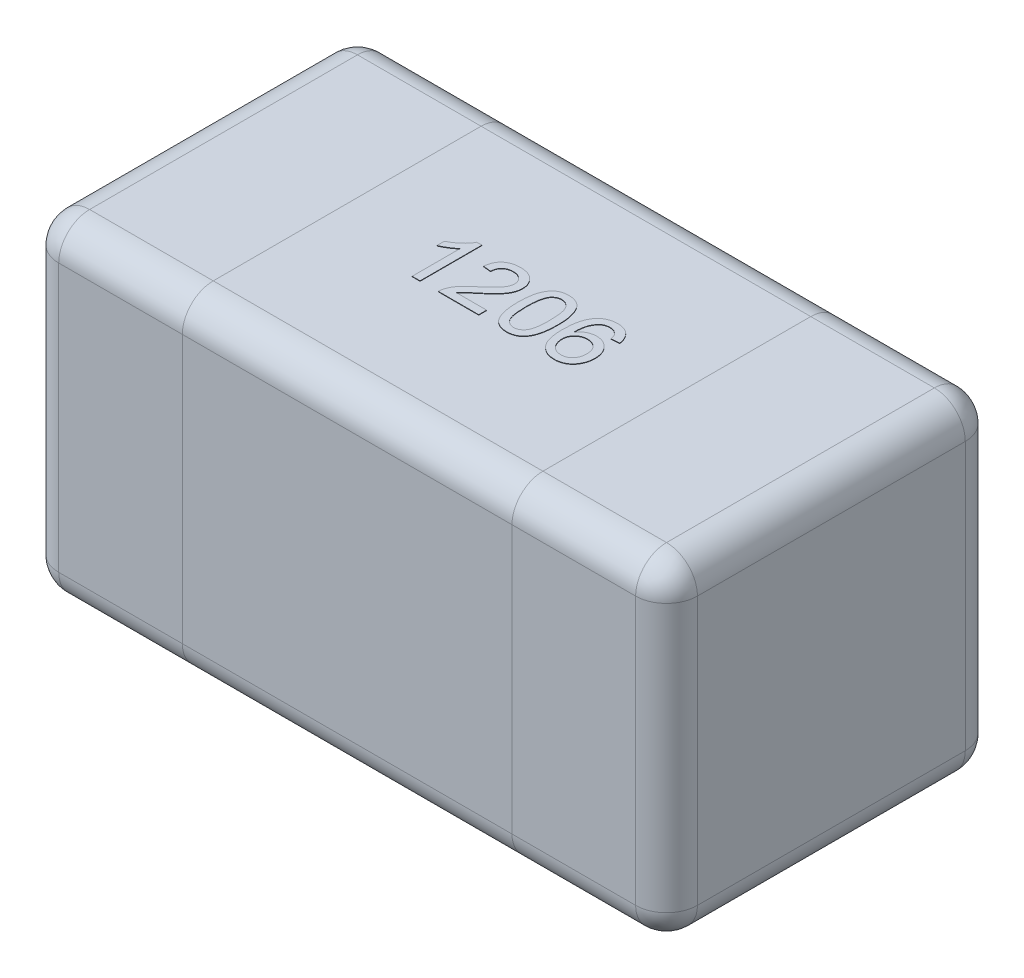
from build123d import *

# Parameters (mm, degrees)
SKETCH1_W      = 3.1
SKETCH1_H      = 1.6
EXTRUDE1_DEPTH = 1.6
FILLET1_R      = 0.15
EXTRUDE2_DEPTH = 0.002


with BuildPart() as part:
    # Sketch1 → Extrude1 (new body)
    with BuildSketch(Plane(origin=(0, 0, 0), x_dir=(1, 0, 0), z_dir=(0, 1, 0))):
        Rectangle(SKETCH1_W, SKETCH1_H)
    extrude(amount=EXTRUDE1_DEPTH)

    # Fillet1
    fillet1_edges = [part.edges().sort_by_distance(p)[0] for p in [
        (1.55, 1.6, 0),
        (0, 1.6, -0.8),
        (-1.55, 1.6, 0),
        (0, 0, -0.8),
        (1.55, 0, 0),
        (0, 0, 0.8),
        (-1.55, 0, 0),
        (0, 1.6, 0.8),
        (-1.55, 0.8, -0.8),
        (1.55, 0.8, -0.8),
        (1.55, 0.8, 0.8),
        (-1.55, 0.8, 0.8),
    ]]
    fillet(fillet1_edges, radius=FILLET1_R)

    # Sketch3 → Extrude2 (add)
    with BuildSketch(Plane(origin=(0, 1.6, 0), x_dir=(1, 0, 0), z_dir=(0, 1, 0))):
        with BuildLine():
            Line((-0.296153846, -0.15), (-0.334615385, -0.15))
            Line((-0.334615385, -0.15), (-0.334615385, 0.083774038))
            add(Edge.make_bspline(
                [(-0.334615385, 0.083774038), (-0.336830003, 0.081638311), (-0.341432846, 0.077199436), (-0.349213465, 0.070917319), (-0.35789763, 0.064550127), (-0.367372572, 0.05842736), (-0.377030672, 0.052663436), (-0.386363982, 0.047479672), (-0.39521668, 0.04309295), (-0.401047999, 0.040694273), (-0.403846154, 0.039543269)],
                knots=[0, 0, 0, 0, 9.226e-06, 1.9175e-05, 2.9969e-05, 4.1521e-05, 5.3002e-05, 6.3707e-05, 7.3544e-05, 8.2619e-05, 8.2619e-05, 8.2619e-05, 8.2619e-05], degree=3))
            Line((-0.403846154, 0.039543269), (-0.403846154, 0.075))
            add(Edge.make_bspline(
                [(-0.403846154, 0.075), (-0.399040034, 0.077475162), (-0.389567455, 0.082353558), (-0.37618475, 0.09077922), (-0.363690555, 0.099912985), (-0.352291699, 0.10975283), (-0.342073351, 0.119810917), (-0.333462201, 0.129959923), (-0.326256938, 0.139827828), (-0.322641922, 0.146709597), (-0.320913462, 0.15)],
                knots=[0, 0, 0, 0, 1.6212e-05, 3.1953e-05, 4.7386e-05, 6.26e-05, 7.7091e-05, 9.0349e-05, 0.000102505, 0.000113642, 0.000113642, 0.000113642, 0.000113642], degree=3))
            Line((-0.320913462, 0.15), (-0.296153846, 0.15))
            Line((-0.296153846, 0.15), (-0.296153846, -0.15))
        make_face()
        with BuildLine():
            Line((-0.011538462, -0.111538462), (-0.011538462, -0.15))
            Line((-0.011538462, -0.15), (-0.207692308, -0.15))
            add(Edge.make_bspline(
                [(-0.207692308, -0.15), (-0.207696323, -0.147714123), (-0.207704342, -0.14315003), (-0.206932024, -0.136400026), (-0.205722419, -0.129739566), (-0.204354719, -0.125468478), (-0.203665865, -0.123317308)],
                knots=[0, 0, 0, 0, 6.852e-06, 1.3681e-05, 2.0352e-05, 2.7121e-05, 2.7121e-05, 2.7121e-05, 2.7121e-05], degree=3))
            add(Edge.make_bspline(
                [(-0.203665865, -0.123317308), (-0.202393093, -0.119802551), (-0.199801518, -0.112645929), (-0.19455096, -0.102319922), (-0.188375063, -0.092056365), (-0.182361958, -0.08370038), (-0.176855252, -0.077024532), (-0.172237162, -0.071801454), (-0.167119471, -0.066455018), (-0.161506278, -0.060986201), (-0.155451607, -0.055359583), (-0.148947197, -0.049556401), (-0.141916239, -0.043684801), (-0.137007895, -0.039792861), (-0.134495192, -0.037800481)],
                knots=[0, 0, 0, 0, 1.1205e-05, 2.2816e-05, 3.4678e-05, 4.712e-05, 5.3653e-05, 6.0635e-05, 6.8031e-05, 7.5851e-05, 8.4142e-05, 9.2826e-05, 0.000101998, 0.000111618, 0.000111618, 0.000111618, 0.000111618], degree=3))
            add(Edge.make_bspline(
                [(-0.134495192, -0.037800481), (-0.130635061, -0.034551471), (-0.123202132, -0.028295295), (-0.112705672, -0.019011711), (-0.103118865, -0.010391377), (-0.094594368, -0.002283205), (-0.087062462, 0.005234162), (-0.080505461, 0.012143692), (-0.074866946, 0.018423822), (-0.070215752, 0.024301865), (-0.066291398, 0.029852373), (-0.062965854, 0.035266551), (-0.060194454, 0.040638972), (-0.057886249, 0.045952637), (-0.056060655, 0.05123027), (-0.054816253, 0.056487246), (-0.053972343, 0.061671403), (-0.053887909, 0.065120999), (-0.053846154, 0.066826923)],
                knots=[0, 0, 0, 0, 1.5136e-05, 2.9145e-05, 4.2036e-05, 5.3811e-05, 6.4435e-05, 7.3957e-05, 8.2386e-05, 8.9745e-05, 9.643e-05, 0.000102769, 0.00010879, 0.00011455, 0.000120137, 0.000125516, 0.000130743, 0.000135857, 0.000135857, 0.000135857, 0.000135857], degree=3))
            add(Edge.make_bspline(
                [(-0.053846154, 0.066826923), (-0.053887914, 0.068512943), (-0.053969845, 0.071820821), (-0.054747201, 0.076661881), (-0.055829343, 0.081323937), (-0.057578837, 0.085723063), (-0.059661262, 0.089989532), (-0.062332474, 0.093988532), (-0.065422517, 0.097819726), (-0.068960356, 0.101382104), (-0.072824504, 0.104724183), (-0.077142138, 0.107502263), (-0.081629679, 0.110003363), (-0.086441941, 0.11201439), (-0.091571106, 0.113491124), (-0.096979835, 0.114562852), (-0.10266727, 0.115242385), (-0.106548545, 0.115336486), (-0.108533654, 0.115384615)],
                knots=[0, 0, 0, 0, 5.054e-06, 9.915e-06, 1.4681e-05, 1.938e-05, 2.4083e-05, 2.89e-05, 3.3772e-05, 3.8829e-05, 4.3946e-05, 4.9063e-05, 5.4199e-05, 5.9345e-05, 6.4669e-05, 7.0185e-05, 7.5872e-05, 8.1827e-05, 8.1827e-05, 8.1827e-05, 8.1827e-05], degree=3))
            add(Edge.make_bspline(
                [(-0.108533654, 0.115384615), (-0.110618956, 0.115336725), (-0.114700045, 0.115242999), (-0.120665504, 0.114560756), (-0.126328674, 0.113518381), (-0.131676037, 0.111924678), (-0.136701084, 0.109917004), (-0.141383351, 0.107389877), (-0.145797819, 0.104537208), (-0.149805459, 0.101159863), (-0.153429516, 0.097415076), (-0.156646835, 0.093338135), (-0.159282944, 0.088850365), (-0.161459952, 0.084050442), (-0.163210448, 0.078923275), (-0.164481249, 0.07342967), (-0.165174098, 0.067585487), (-0.165313425, 0.063583392), (-0.165384615, 0.061538462)],
                knots=[0, 0, 0, 0, 6.255e-06, 1.2241e-05, 1.7992e-05, 2.3507e-05, 2.8953e-05, 3.4195e-05, 3.9446e-05, 4.4693e-05, 4.9878e-05, 5.506e-05, 6.0233e-05, 6.5451e-05, 7.0848e-05, 7.6461e-05, 8.2334e-05, 8.8471e-05, 8.8471e-05, 8.8471e-05, 8.8471e-05], degree=3))
            Line((-0.165384615, 0.061538462), (-0.203846154, 0.065384615))
            add(Edge.make_bspline(
                [(-0.203846154, 0.065384615), (-0.203452638, 0.068736632), (-0.202687086, 0.075257693), (-0.200780201, 0.084702351), (-0.198103106, 0.09348859), (-0.194899737, 0.101738909), (-0.190884012, 0.109312863), (-0.18634458, 0.11636711), (-0.18099053, 0.122677919), (-0.175075725, 0.128444216), (-0.168535362, 0.133525841), (-0.161430878, 0.137965346), (-0.153765522, 0.141678718), (-0.145581988, 0.144753235), (-0.136861488, 0.147085948), (-0.12761636, 0.148758724), (-0.117831734, 0.149789842), (-0.111120341, 0.149928948), (-0.107692308, 0.15)],
                knots=[0, 0, 0, 0, 1.0123e-05, 1.9693e-05, 2.8857e-05, 3.7651e-05, 4.6199e-05, 5.4533e-05, 6.2766e-05, 7.0968e-05, 7.9275e-05, 8.7563e-05, 9.6056e-05, 0.000104785, 0.00011375, 0.000123098, 0.000132946, 0.000143229, 0.000143229, 0.000143229, 0.000143229], degree=3))
            add(Edge.make_bspline(
                [(-0.107692308, 0.15), (-0.104223243, 0.149940596), (-0.097465484, 0.149824877), (-0.087618344, 0.14864084), (-0.078327294, 0.146796713), (-0.069558275, 0.144226564), (-0.061363096, 0.140856333), (-0.053735451, 0.136738671), (-0.046640172, 0.131913745), (-0.040195807, 0.126323636), (-0.034384754, 0.120221095), (-0.029292223, 0.113708369), (-0.025034622, 0.106813279), (-0.021409539, 0.09962981), (-0.018720681, 0.092006182), (-0.016829827, 0.084046037), (-0.015544936, 0.075742575), (-0.015438766, 0.070077103), (-0.015384615, 0.0671875)],
                knots=[0, 0, 0, 0, 1.0403e-05, 2.0265e-05, 2.9705e-05, 3.8794e-05, 4.7633e-05, 5.6238e-05, 6.4755e-05, 7.3321e-05, 8.178e-05, 9.0002e-05, 9.8073e-05, 0.000106055, 0.000114096, 0.000122258, 0.000130579, 0.00013924, 0.00013924, 0.00013924, 0.00013924], degree=3))
            add(Edge.make_bspline(
                [(-0.015384615, 0.0671875), (-0.015467303, 0.06421876), (-0.01563286, 0.058274728), (-0.016925056, 0.049390154), (-0.019136019, 0.040601997), (-0.022067165, 0.0318033), (-0.026071721, 0.022959142), (-0.031130797, 0.013947517), (-0.037407134, 0.004735138), (-0.04344321, -0.003096409), (-0.049061817, -0.009661219), (-0.054042181, -0.015064442), (-0.059804175, -0.020805005), (-0.066131643, -0.027081717), (-0.073282651, -0.033671804), (-0.081051734, -0.040772611), (-0.089608959, -0.048197271), (-0.095549342, -0.053269443), (-0.098617788, -0.055889423)],
                knots=[0, 0, 0, 0, 8.904e-06, 1.7828e-05, 2.6865e-05, 3.6063e-05, 4.5612e-05, 5.5944e-05, 6.7028e-05, 7.9024e-05, 8.5588e-05, 9.2946e-05, 0.000101063, 0.000109987, 0.000119681, 0.000130232, 0.000141562, 0.000153666, 0.000153666, 0.000153666, 0.000153666], degree=3))
            add(Edge.make_bspline(
                [(-0.098617788, -0.055889423), (-0.101245449, -0.058028619), (-0.106255994, -0.062107737), (-0.113384465, -0.068021343), (-0.119769407, -0.07344396), (-0.12556013, -0.078198712), (-0.130545741, -0.08251558), (-0.13490185, -0.086205504), (-0.138470198, -0.089454013), (-0.14390416, -0.094388563), (-0.150786737, -0.101422266), (-0.155858114, -0.108256719), (-0.158293269, -0.111538462)],
                knots=[0, 0, 0, 0, 1.0165e-05, 1.9383e-05, 2.7786e-05, 3.5295e-05, 4.1859e-05, 4.7569e-05, 5.242e-05, 5.6334e-05, 6.9594e-05, 8.1844e-05, 8.1844e-05, 8.1844e-05, 8.1844e-05], degree=3))
            Line((-0.158293269, -0.111538462), (-0.011538462, -0.111538462))
        make_face()
        with BuildLine():
            add(Edge.make_bspline(
                [(0.030769231, -0.002043269), (0.030807981, 0.002244006), (0.030883876, 0.010640973), (0.031354627, 0.022927244), (0.032176522, 0.034595007), (0.033403384, 0.045634129), (0.034856218, 0.056069528), (0.036744912, 0.06588631), (0.038869967, 0.075106502), (0.041419652, 0.083720493), (0.044220921, 0.091802347), (0.047399051, 0.0993391), (0.050974877, 0.106322761), (0.054772671, 0.112825754), (0.058992356, 0.118746931), (0.063379241, 0.124252464), (0.068252138, 0.129140445), (0.073408422, 0.13353664), (0.07892402, 0.137416027), (0.084769749, 0.140763469), (0.090923117, 0.143719019), (0.097501399, 0.145943957), (0.104368033, 0.147757753), (0.111575873, 0.149092003), (0.119132863, 0.149878588), (0.124297003, 0.149959072), (0.126923077, 0.15)],
                knots=[0, 0, 0, 0, 1.2862e-05, 2.5191e-05, 3.688e-05, 4.7943e-05, 5.8507e-05, 6.8478e-05, 7.7924e-05, 8.6881e-05, 9.5415e-05, 0.000103574, 0.000111395, 0.00011894, 0.000126142, 0.000133191, 0.000140033, 0.000146812, 0.000153498, 0.000160229, 0.000167003, 0.000173941, 0.000181025, 0.000188297, 0.00019591, 0.000203786, 0.000203786, 0.000203786, 0.000203786], degree=3))
            add(Edge.make_bspline(
                [(0.126923077, 0.15), (0.130775868, 0.149886731), (0.138344831, 0.149664209), (0.149395556, 0.147849358), (0.159810153, 0.144744777), (0.169581854, 0.140556563), (0.178543614, 0.135236725), (0.186546843, 0.128769652), (0.193505214, 0.121223246), (0.199342787, 0.112508085), (0.204445409, 0.102864591), (0.208978466, 0.092249481), (0.213076217, 0.080674651), (0.215984071, 0.070313561), (0.218058241, 0.061369501), (0.219431176, 0.053992694), (0.220570988, 0.046033077), (0.221444238, 0.037509907), (0.222160719, 0.028432744), (0.222714024, 0.018795935), (0.222994883, 0.008575397), (0.223049064, 0.001562641), (0.223076923, -0.002043269)],
                knots=[0, 0, 0, 0, 1.1554e-05, 2.2698e-05, 3.348e-05, 4.4085e-05, 5.4516e-05, 6.4643e-05, 7.485e-05, 8.5185e-05, 9.602e-05, 0.000107541, 0.000119781, 0.000132832, 0.000139801, 0.000147321, 0.000155335, 0.000163916, 0.000173019, 0.00018265, 0.000192871, 0.000203689, 0.000203689, 0.000203689, 0.000203689], degree=3))
            add(Edge.make_bspline(
                [(0.223076923, -0.002043269), (0.223037447, -0.006310407), (0.222960323, -0.0146471), (0.222502186, -0.026834856), (0.221630766, -0.038414591), (0.220558469, -0.049412832), (0.218936308, -0.059800218), (0.217188341, -0.069620882), (0.215026538, -0.07883023), (0.212504222, -0.087432298), (0.209663521, -0.095472571), (0.206548253, -0.103011813), (0.203097794, -0.110044871), (0.199209446, -0.11650315), (0.195061119, -0.122472371), (0.190622429, -0.127974928), (0.185799273, -0.132931621), (0.180596523, -0.137314631), (0.175119652, -0.141262812), (0.16925971, -0.144643304), (0.163042348, -0.147443983), (0.156509104, -0.149838424), (0.149593689, -0.15159293), (0.142350639, -0.152935977), (0.134753266, -0.153726861), (0.129569151, -0.153805841), (0.126923077, -0.153846154)],
                knots=[0, 0, 0, 0, 1.2802e-05, 2.5011e-05, 3.658e-05, 4.7637e-05, 5.815e-05, 6.811e-05, 7.7556e-05, 8.6513e-05, 9.499e-05, 0.000103126, 0.000110974, 0.000118467, 0.000125719, 0.000132767, 0.000139652, 0.000146431, 0.000153152, 0.000159883, 0.000166686, 0.000173587, 0.000180729, 0.000188061, 0.000195673, 0.00020361, 0.00020361, 0.00020361, 0.00020361], degree=3))
            add(Edge.make_bspline(
                [(0.126923077, -0.153846154), (0.123453767, -0.153747192), (0.116689568, -0.153554242), (0.106810954, -0.152243272), (0.097539347, -0.149935902), (0.088796548, -0.146841394), (0.080680827, -0.142702311), (0.073153436, -0.137666308), (0.066063116, -0.131850554), (0.061981497, -0.127262057), (0.059915865, -0.124939904)],
                knots=[0, 0, 0, 0, 1.0408e-05, 2.0292e-05, 2.9825e-05, 3.9025e-05, 4.8056e-05, 5.7073e-05, 6.616e-05, 7.5471e-05, 7.5471e-05, 7.5471e-05, 7.5471e-05], degree=3))
            add(Edge.make_bspline(
                [(0.059915865, -0.124939904), (0.057538275, -0.121510195), (0.052635583, -0.11443799), (0.046897407, -0.102379223), (0.041778852, -0.089104214), (0.037761725, -0.074352508), (0.034615313, -0.058241513), (0.032342818, -0.040739616), (0.031056809, -0.021854376), (0.030867254, -0.008796046), (0.030769231, -0.002043269)],
                knots=[0, 0, 0, 0, 1.2501e-05, 2.5778e-05, 3.993e-05, 5.5152e-05, 7.157e-05, 8.9147e-05, 0.000108063, 0.000128321, 0.000128321, 0.000128321, 0.000128321], degree=3))
        make_face()
        with BuildLine():
            add(Edge.make_bspline(
                [(0.069230769, -0.001923077), (0.069268958, -0.007693168), (0.069342061, -0.018738399), (0.070105807, -0.034518417), (0.071420563, -0.048754147), (0.073158757, -0.061425879), (0.075453876, -0.072550754), (0.07833567, -0.082100422), (0.081584138, -0.090189501), (0.085604055, -0.096717734), (0.090005419, -0.102039196), (0.094549528, -0.106615825), (0.099343287, -0.110505855), (0.104355418, -0.113749347), (0.109663688, -0.116205105), (0.115210052, -0.117985045), (0.120995717, -0.119009373), (0.124936017, -0.119156549), (0.126923077, -0.119230769)],
                knots=[0, 0, 0, 0, 1.7309e-05, 3.3134e-05, 4.7378e-05, 6.0186e-05, 7.1489e-05, 8.1413e-05, 9.0085e-05, 9.7558e-05, 0.000104306, 0.000110765, 0.000116876, 0.000122794, 0.000128628, 0.000134368, 0.000140227, 0.000146187, 0.000146187, 0.000146187, 0.000146187], degree=3))
            add(Edge.make_bspline(
                [(0.126923077, -0.119230769), (0.128909639, -0.119154928), (0.132848953, -0.119004535), (0.138647986, -0.118002795), (0.14417277, -0.116131225), (0.149473125, -0.11368414), (0.154521686, -0.110514577), (0.159291902, -0.106609854), (0.163859948, -0.102035942), (0.168241542, -0.096652628), (0.172230832, -0.090094213), (0.175540237, -0.082011723), (0.17837712, -0.072445331), (0.180684833, -0.061326124), (0.182430197, -0.048674427), (0.183737005, -0.03447818), (0.184505861, -0.018718466), (0.184577757, -0.007693194), (0.184615385, -0.001923077)],
                knots=[0, 0, 0, 0, 5.96e-06, 1.1819e-05, 1.7578e-05, 2.3412e-05, 2.9298e-05, 3.5408e-05, 4.1867e-05, 4.8662e-05, 5.6186e-05, 6.4803e-05, 7.4784e-05, 8.6088e-05, 9.8836e-05, 0.00011308, 0.000128845, 0.000146154, 0.000146154, 0.000146154, 0.000146154], degree=3))
            add(Edge.make_bspline(
                [(0.184615385, -0.001923077), (0.184578962, 0.003726983), (0.184509178, 0.014552283), (0.183720492, 0.030028299), (0.182484549, 0.044025088), (0.180793976, 0.056555555), (0.178547205, 0.067606095), (0.175822177, 0.077200235), (0.1725749, 0.085317512), (0.168713899, 0.092039466), (0.164415832, 0.097553292), (0.159926094, 0.102325988), (0.15513244, 0.10638501), (0.149949942, 0.109641218), (0.144545641, 0.112268205), (0.13879536, 0.114076165), (0.13275562, 0.115186918), (0.128610625, 0.115317963), (0.126502404, 0.115384615)],
                knots=[0, 0, 0, 0, 1.6949e-05, 3.2473e-05, 4.6473e-05, 5.9094e-05, 7.0385e-05, 8.0274e-05, 8.8979e-05, 9.6545e-05, 0.000103444, 0.000109906, 0.000116177, 0.000122229, 0.000128223, 0.000134153, 0.000140259, 0.000146579, 0.000146579, 0.000146579, 0.000146579], degree=3))
            add(Edge.make_bspline(
                [(0.126502404, 0.115384615), (0.124515469, 0.115332466), (0.120597487, 0.115229635), (0.114861049, 0.114248109), (0.109424694, 0.112606778), (0.104226139, 0.110383437), (0.099395163, 0.107391258), (0.094740182, 0.103897677), (0.090479217, 0.099641138), (0.087911597, 0.096459016), (0.086598558, 0.094831731)],
                knots=[0, 0, 0, 0, 5.957e-06, 1.1747e-05, 1.7393e-05, 2.2965e-05, 2.8654e-05, 3.4399e-05, 4.0391e-05, 4.6662e-05, 4.6662e-05, 4.6662e-05, 4.6662e-05], degree=3))
            add(Edge.make_bspline(
                [(0.086598558, 0.094831731), (0.085169059, 0.092441753), (0.082150258, 0.087394622), (0.078772395, 0.078622501), (0.075788524, 0.068597636), (0.07333181, 0.057165788), (0.071554549, 0.044346567), (0.07015147, 0.03015486), (0.069422623, 0.014570853), (0.069296485, 0.003726591), (0.069230769, -0.001923077)],
                knots=[0, 0, 0, 0, 8.341e-06, 1.7615e-05, 2.8091e-05, 3.9714e-05, 5.2649e-05, 6.6899e-05, 8.2483e-05, 9.9433e-05, 9.9433e-05, 9.9433e-05, 9.9433e-05], degree=3))
        make_face(mode=Mode.SUBTRACT)
        with BuildLine():
            Line((0.45, 0.073076923), (0.411538462, 0.069230769))
            add(Edge.make_bspline(
                [(0.411538462, 0.069230769), (0.410708492, 0.072538667), (0.409146203, 0.078765275), (0.405870098, 0.087210729), (0.4022599, 0.094354147), (0.399123422, 0.09820068), (0.39765625, 0.1)],
                knots=[0, 0, 0, 0, 1.022e-05, 1.9238e-05, 2.7142e-05, 3.4089e-05, 3.4089e-05, 3.4089e-05, 3.4089e-05], degree=3))
            add(Edge.make_bspline(
                [(0.39765625, 0.1), (0.396396853, 0.101227235), (0.393919912, 0.103640922), (0.389853676, 0.10678718), (0.385567189, 0.109452847), (0.381047498, 0.111612442), (0.376319018, 0.113318398), (0.371362165, 0.114511805), (0.366188166, 0.115250592), (0.362662732, 0.115339561), (0.360877404, 0.115384615)],
                knots=[0, 0, 0, 0, 5.272e-06, 1.0369e-05, 1.5389e-05, 2.0388e-05, 2.5369e-05, 3.0441e-05, 3.5659e-05, 4.1013e-05, 4.1013e-05, 4.1013e-05, 4.1013e-05], degree=3))
            add(Edge.make_bspline(
                [(0.360877404, 0.115384615), (0.357983079, 0.115291422), (0.352264021, 0.115107275), (0.343873139, 0.113304494), (0.335723235, 0.110606344), (0.330674068, 0.107871213), (0.328125, 0.106490385)],
                knots=[0, 0, 0, 0, 8.671e-06, 1.7133e-05, 2.5647e-05, 3.4328e-05, 3.4328e-05, 3.4328e-05, 3.4328e-05], degree=3))
            add(Edge.make_bspline(
                [(0.328125, 0.106490385), (0.32561815, 0.104413394), (0.320472186, 0.10014983), (0.313756639, 0.092271657), (0.307751014, 0.08309911), (0.303321758, 0.074535839), (0.300204588, 0.066858114), (0.298188572, 0.060278069), (0.296466137, 0.053008475), (0.295031251, 0.045063026), (0.29392146, 0.036435278), (0.292993896, 0.027119753), (0.292480875, 0.017092829), (0.292366611, 0.010176786), (0.292307692, 0.006610577)],
                knots=[0, 0, 0, 0, 9.752e-06, 2.0019e-05, 3.0903e-05, 4.2594e-05, 4.8877e-05, 5.5739e-05, 6.3217e-05, 7.1279e-05, 7.9949e-05, 8.9307e-05, 9.9358e-05, 0.000110058, 0.000110058, 0.000110058, 0.000110058], degree=3))
            add(Edge.make_bspline(
                [(0.292307692, 0.006610577), (0.294575255, 0.009796435), (0.299014148, 0.016032946), (0.30684469, 0.024190765), (0.31539528, 0.031086712), (0.324675478, 0.036592663), (0.334443135, 0.040859911), (0.344482862, 0.04393058), (0.354777063, 0.045815439), (0.3617109, 0.04604047), (0.365204327, 0.046153846)],
                knots=[0, 0, 0, 0, 1.1719e-05, 2.294e-05, 3.3799e-05, 4.458e-05, 5.5209e-05, 6.5703e-05, 7.6018e-05, 8.6492e-05, 8.6492e-05, 8.6492e-05, 8.6492e-05], degree=3))
            add(Edge.make_bspline(
                [(0.365204327, 0.046153846), (0.368213024, 0.046072896), (0.374157277, 0.045912965), (0.382910862, 0.044645582), (0.391302971, 0.042428842), (0.399406328, 0.03954103), (0.407065214, 0.035598019), (0.414466549, 0.0309898), (0.421438918, 0.025382127), (0.428070563, 0.019081266), (0.434108418, 0.012076111), (0.439452347, 0.004536569), (0.443905634, -0.003555431), (0.447516735, -0.012145696), (0.450343053, -0.021202968), (0.452396708, -0.030752967), (0.45359889, -0.040814567), (0.453762628, -0.047693081), (0.453846154, -0.051201923)],
                knots=[0, 0, 0, 0, 9.024e-06, 1.7829e-05, 2.6458e-05, 3.5032e-05, 4.3579e-05, 5.2249e-05, 6.1146e-05, 7.037e-05, 7.9659e-05, 8.8846e-05, 9.8045e-05, 0.000107309, 0.000116756, 0.000126468, 0.000136576, 0.000147101, 0.000147101, 0.000147101, 0.000147101], degree=3))
            add(Edge.make_bspline(
                [(0.453846154, -0.051201923), (0.453696506, -0.055839129), (0.453401179, -0.064990544), (0.45103072, -0.078467226), (0.447211078, -0.091457445), (0.442641819, -0.101744572), (0.438443862, -0.109625611), (0.434879306, -0.115137959), (0.431067791, -0.120318178), (0.427081512, -0.12523755), (0.422631343, -0.129670926), (0.417987077, -0.133827203), (0.412995205, -0.137562688), (0.407802543, -0.141001671), (0.402310998, -0.143983621), (0.396680359, -0.146633405), (0.390864275, -0.148890534), (0.384843967, -0.150662761), (0.378650268, -0.152128961), (0.372262562, -0.153137108), (0.365697661, -0.153758859), (0.361259417, -0.15381683), (0.359014423, -0.153846154)],
                knots=[0, 0, 0, 0, 1.3904e-05, 2.744e-05, 4.0921e-05, 5.443e-05, 6.1126e-05, 6.7694e-05, 7.4101e-05, 8.0418e-05, 8.6665e-05, 9.2923e-05, 9.9101e-05, 0.000105352, 0.000111591, 0.000117829, 0.000124012, 0.000130286, 0.000136642, 0.000143093, 0.000149671, 0.000156404, 0.000156404, 0.000156404, 0.000156404], degree=3))
            add(Edge.make_bspline(
                [(0.359014423, -0.153846154), (0.355223048, -0.153741017), (0.347787494, -0.153534825), (0.336904474, -0.151950766), (0.32657057, -0.14930358), (0.316763801, -0.145602515), (0.307454292, -0.140929997), (0.298733786, -0.135072673), (0.290554031, -0.128204222), (0.28290872, -0.120284809), (0.275976723, -0.11114027), (0.270052326, -0.100584666), (0.265004214, -0.088710395), (0.260872774, -0.075484787), (0.257746467, -0.060894011), (0.255495393, -0.044969404), (0.254111008, -0.027708685), (0.253936503, -0.015747884), (0.253846154, -0.009555288)],
                knots=[0, 0, 0, 0, 1.1371e-05, 2.2301e-05, 3.2912e-05, 4.3315e-05, 5.3689e-05, 6.409e-05, 7.4754e-05, 8.5677e-05, 9.7048e-05, 0.000109078, 0.000121893, 0.000135692, 0.00015058, 0.000166609, 0.000183912, 0.000202488, 0.000202488, 0.000202488, 0.000202488], degree=3))
            add(Edge.make_bspline(
                [(0.253846154, -0.009555288), (0.253861135, -0.006029025), (0.253890683, 0.000925972), (0.25436549, 0.011161994), (0.254910152, 0.021047347), (0.255843344, 0.030542594), (0.256945199, 0.039690441), (0.258423875, 0.048437091), (0.260011794, 0.056850531), (0.26194238, 0.06486452), (0.264094511, 0.072554447), (0.266571688, 0.079835817), (0.269188202, 0.086802839), (0.272156581, 0.093345608), (0.275320183, 0.099570683), (0.278817081, 0.105362867), (0.282484377, 0.1108546), (0.285191728, 0.114240976), (0.286538462, 0.115925481)],
                knots=[0, 0, 0, 0, 1.0578e-05, 2.0863e-05, 3.0737e-05, 4.0275e-05, 4.948e-05, 5.8372e-05, 6.6882e-05, 7.5161e-05, 8.3094e-05, 9.0829e-05, 9.8228e-05, 0.00010541, 0.000112371, 0.000119163, 0.000125697, 0.000132165, 0.000132165, 0.000132165, 0.000132165], degree=3))
            add(Edge.make_bspline(
                [(0.286538462, 0.115925481), (0.288961211, 0.118650597), (0.293736676, 0.124022054), (0.301905995, 0.130960705), (0.310611092, 0.136887379), (0.319990804, 0.14167562), (0.32997344, 0.145408685), (0.340565259, 0.14811856), (0.351795817, 0.149690101), (0.359470198, 0.149895026), (0.363401442, 0.15)],
                knots=[0, 0, 0, 0, 1.0928e-05, 2.154e-05, 3.2057e-05, 4.2459e-05, 5.3051e-05, 6.3969e-05, 7.5196e-05, 8.6987e-05, 8.6987e-05, 8.6987e-05, 8.6987e-05], degree=3))
            add(Edge.make_bspline(
                [(0.363401442, 0.15), (0.36632869, 0.149948255), (0.372079505, 0.149846599), (0.380505916, 0.148871193), (0.388520914, 0.147240948), (0.39614235, 0.145041931), (0.403325908, 0.142114758), (0.410154404, 0.138645741), (0.416558502, 0.134472732), (0.422491839, 0.129652743), (0.427969112, 0.124322407), (0.432875029, 0.118436964), (0.437191105, 0.112069766), (0.440951092, 0.10520757), (0.444121392, 0.097882861), (0.446724366, 0.090064157), (0.4487028, 0.081753468), (0.449561606, 0.076009194), (0.45, 0.073076923)],
                knots=[0, 0, 0, 0, 8.779e-06, 1.7247e-05, 2.5403e-05, 3.3295e-05, 4.1006e-05, 4.864e-05, 5.624e-05, 6.389e-05, 7.1539e-05, 7.9134e-05, 8.6834e-05, 9.458e-05, 0.000102574, 0.000110746, 0.000119273, 0.000128165, 0.000128165, 0.000128165, 0.000128165], degree=3))
        make_face()
        with BuildLine():
            add(Edge.make_bspline(
                [(0.292307692, -0.050420673), (0.292414672, -0.053432194), (0.292627226, -0.0594157), (0.294253022, -0.068297189), (0.296908061, -0.076962701), (0.300546824, -0.085315996), (0.305040025, -0.093077055), (0.310376901, -0.099953889), (0.316441609, -0.105845529), (0.323201556, -0.110764759), (0.330640875, -0.114545052), (0.338626325, -0.117282967), (0.347167448, -0.118937772), (0.353057469, -0.119131628), (0.356069712, -0.119230769)],
                knots=[0, 0, 0, 0, 9.031e-06, 1.7943e-05, 2.6992e-05, 3.6169e-05, 4.5219e-05, 5.3826e-05, 6.2198e-05, 7.0505e-05, 7.881e-05, 8.7134e-05, 9.5761e-05, 0.000104792, 0.000104792, 0.000104792, 0.000104792], degree=3))
            add(Edge.make_bspline(
                [(0.356069712, -0.119230769), (0.358216277, -0.119172715), (0.362406182, -0.1190594), (0.368540884, -0.118181315), (0.374394068, -0.116831083), (0.379931842, -0.114836124), (0.38514669, -0.112290008), (0.390065691, -0.109191217), (0.394685661, -0.105530475), (0.398950744, -0.1013145), (0.402805456, -0.096625578), (0.406154689, -0.091492483), (0.409112375, -0.085999667), (0.411337027, -0.080012147), (0.413149797, -0.073683317), (0.414482528, -0.066953335), (0.415264982, -0.059814476), (0.41534416, -0.05490983), (0.415384615, -0.052403846)],
                knots=[0, 0, 0, 0, 6.437e-06, 1.2565e-05, 1.8556e-05, 2.443e-05, 3.0181e-05, 3.5934e-05, 4.1837e-05, 4.7829e-05, 5.3893e-05, 6.001e-05, 6.6193e-05, 7.2565e-05, 7.9128e-05, 8.5928e-05, 9.3122e-05, 0.000100638, 0.000100638, 0.000100638, 0.000100638], degree=3))
            add(Edge.make_bspline(
                [(0.415384615, -0.052403846), (0.415347094, -0.049997387), (0.415273715, -0.045291251), (0.414448055, -0.038423999), (0.413245266, -0.031932012), (0.411398846, -0.025869914), (0.409132681, -0.020173529), (0.406293201, -0.014885466), (0.40298467, -0.009960784), (0.399105553, -0.005529883), (0.394863462, -0.001493073), (0.390204523, 0.002013282), (0.38518465, 0.00497459), (0.379785734, 0.007398919), (0.373997604, 0.009256882), (0.367832247, 0.010544495), (0.361324353, 0.011443306), (0.356854182, 0.011506257), (0.354567308, 0.011538462)],
                knots=[0, 0, 0, 0, 7.216e-06, 1.4111e-05, 2.0723e-05, 2.6997e-05, 3.309e-05, 3.9086e-05, 4.497e-05, 5.0849e-05, 5.6716e-05, 6.2509e-05, 6.8302e-05, 7.4165e-05, 8.0228e-05, 8.6499e-05, 9.3043e-05, 9.9899e-05, 9.9899e-05, 9.9899e-05, 9.9899e-05], degree=3))
            add(Edge.make_bspline(
                [(0.354567308, 0.011538462), (0.352440511, 0.011505232), (0.348249457, 0.01143975), (0.342103239, 0.010533926), (0.336179534, 0.009243732), (0.330501992, 0.007366681), (0.325068659, 0.004949397), (0.319880741, 0.002009058), (0.314983289, -0.001538568), (0.310331648, -0.005511501), (0.306087081, -0.009924881), (0.302363096, -0.014699634), (0.299325657, -0.019866478), (0.296670442, -0.02529901), (0.294725059, -0.031125292), (0.293340895, -0.03726721), (0.292482748, -0.0437259), (0.292366952, -0.048154362), (0.292307692, -0.050420673)],
                knots=[0, 0, 0, 0, 6.375e-06, 1.2562e-05, 1.8598e-05, 2.4546e-05, 3.0465e-05, 3.6413e-05, 4.24e-05, 4.858e-05, 5.4743e-05, 6.0741e-05, 6.6698e-05, 7.2692e-05, 7.885e-05, 8.5075e-05, 9.156e-05, 9.8358e-05, 9.8358e-05, 9.8358e-05, 9.8358e-05], degree=3))
        make_face(mode=Mode.SUBTRACT)
    extrude(amount=EXTRUDE2_DEPTH)


solid = part.part
